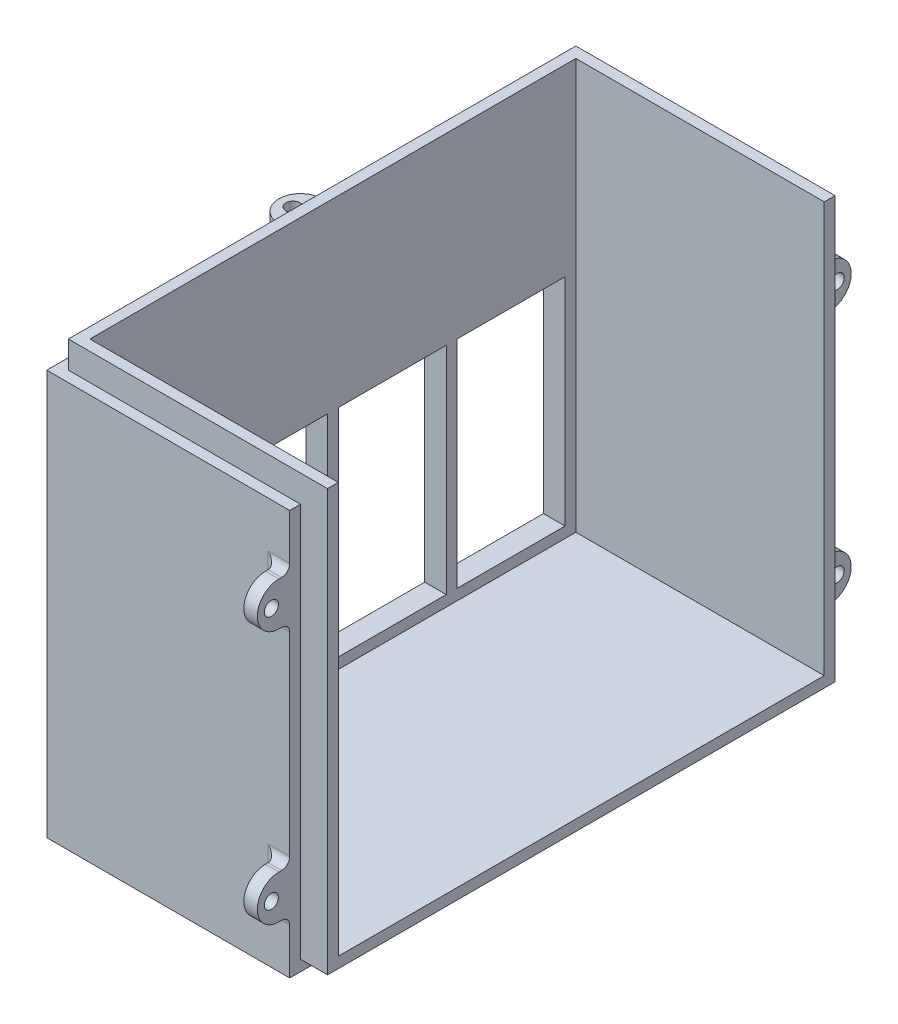
from build123d import *

# Parameters (mm, degrees)
SKETCH1_W           = 50
SKETCH1_H           = 98
BOSS_EXTRUDE3_DEPTH = 80
SKETCH4_W           = 90
SKETCH4_H           = 76
CUT_EXTRUDE2_DEPTH  = 46
SKETCH6_W           = 48
SKETCH6_H           = 2
CUT_EXTRUDE3_DEPTH  = 5
SKETCH7_W           = 2
SKETCH7_H           = 73
CUT_EXTRUDE4_DEPTH  = 5
SKETCH10_R          = 1.3
BOSS_EXTRUDE6_DEPTH = 2.5
FILLET2_R           = 1.5
FILLET3_R           = 1.5
SKETCH12_R          = 1.3
BOSS_EXTRUDE7_DEPTH = 2.5
FILLET4_R           = 1.5
CUT_EXTRUDE5_REACH  = 52
SKETCH14_W          = 20
SKETCH14_H          = 40


with BuildPart() as part:
    # Sketch1 → Boss-Extrude3 (new body)
    with BuildSketch(Plane(origin=(0, 0, 0), x_dir=(1, 0, 0), z_dir=(0, 1, 0))):
        Rectangle(SKETCH1_W, SKETCH1_H)
    extrude(amount=BOSS_EXTRUDE3_DEPTH)

    # Sketch4 → Cut-Extrude2 (cut)
    with BuildSketch(Plane(origin=(25, 0, 0), x_dir=(0, 0, -1), z_dir=(1, 0, 0))):
        with Locations((0, 42)):
            Rectangle(SKETCH4_W, SKETCH4_H)
    extrude(amount=-CUT_EXTRUDE2_DEPTH, mode=Mode.SUBTRACT)

    # Sketch6 → Cut-Extrude3 (cut)
    with BuildSketch(Plane(origin=(0, 80, 0), x_dir=(1, 0, 0), z_dir=(0, 1, 0))):
        with Locations((1, 48)):
            Rectangle(SKETCH6_W, SKETCH6_H)
        Polygon((-25, 49), (-25, -47), (-23, -47), (-23, 47), (-23, 49), align=None)
        Polygon((-25, -49), (25, -49), (25, -47), (-23, -47), (-25, -47), align=None)
    extrude(amount=-CUT_EXTRUDE3_DEPTH, mode=Mode.SUBTRACT)

    # Sketch7 → Cut-Extrude4 (cut)
    with BuildSketch(Plane(origin=(25, 0, 0), x_dir=(0, 0, -1), z_dir=(1, 0, 0))):
        Polygon((-47, 75), (-49, 75), (-49, 0), (-47, 0), (-47, 2), align=None)
        Polygon((47, 2), (-47, 2), (-47, 0), (49, 0), (49, 2), align=None)
        with Locations((48, 38.5)):
            Rectangle(SKETCH7_W, SKETCH7_H)
    extrude(amount=-CUT_EXTRUDE4_DEPTH, mode=Mode.SUBTRACT)

    # Sketch10 → Boss-Extrude6 (add)
    with BuildSketch(Plane(origin=(20, 0, 0), x_dir=(0, 0, -1), z_dir=(1, 0, 0))):
        with BuildLine():
            Line((-49, 10), (-51, 10))
            ThreePointArc((-51, 10), (-55, 14), (-51, 18))
            Line((-51, 18), (-49, 18))
            Line((-49, 18), (-49, 10))
        make_face()
        with Locations((-52.4, 14)):
            Circle(SKETCH10_R, mode=Mode.SUBTRACT)
        with BuildLine():
            Line((-49, 65), (-49, 57))
            Line((-49, 57), (-51, 57))
            ThreePointArc((-51, 57), (-55, 61), (-51, 65))
            Line((-51, 65), (-49, 65))
        make_face()
        with Locations((-52.4, 61)):
            Circle(SKETCH10_R, mode=Mode.SUBTRACT)
        with BuildLine():
            Line((49, 10), (49, 18))
            Line((49, 18), (51, 18))
            ThreePointArc((51, 18), (55, 14), (51, 10))
            Line((51, 10), (49, 10))
        make_face()
        with Locations((52.4, 14)):
            Circle(SKETCH10_R, mode=Mode.SUBTRACT)
        with BuildLine():
            Line((49, 65), (51, 65))
            ThreePointArc((51, 65), (55, 61), (51, 57))
            Line((51, 57), (49, 57))
            Line((49, 57), (49, 65))
        make_face()
        with Locations((52.4, 61)):
            Circle(SKETCH10_R, mode=Mode.SUBTRACT)
    extrude(amount=-BOSS_EXTRUDE6_DEPTH)

    # Fillet2
    fillet2_edges = [part.edges().sort_by_distance(p)[0] for p in [
        (17.5, 61, 49),
        (18.75, 65, 49),
        (18.75, 57, 49),
        (17.5, 14, 49),
        (18.75, 18, 49),
        (18.75, 10, 49),
    ]]
    fillet(fillet2_edges, radius=FILLET2_R)

    # Fillet3
    fillet3_edges = [part.edges().sort_by_distance(p)[0] for p in [
        (17.5, 14, -49),
        (18.75, 10, -49),
        (18.75, 18, -49),
        (17.5, 61, -49),
        (18.75, 57, -49),
        (18.75, 65, -49),
    ]]
    fillet(fillet3_edges, radius=FILLET3_R)

    # Sketch12 → Boss-Extrude7 (add)
    with BuildSketch(Plane(origin=(0, 75, 0), x_dir=(1, 0, 0), z_dir=(0, 1, 0))):
        with BuildLine():
            Line((-25, 4), (-27, 4))
            ThreePointArc((-27, 4), (-31, 0), (-27, -4))
            Line((-27, -4), (-25, -4))
            Line((-25, -4), (-25, 4))
        make_face()
        with Locations((-28.4, 0)):
            Circle(SKETCH12_R, mode=Mode.SUBTRACT)
    extrude(amount=-BOSS_EXTRUDE7_DEPTH)

    # Fillet4
    fillet4_edges = [part.edges().sort_by_distance(p)[0] for p in [
        (-25, 72.5, 0),
        (-25, 73.75, -4),
        (-25, 73.75, 4),
    ]]
    fillet(fillet4_edges, radius=FILLET4_R)

    # Sketch14 → Cut-Extrude5 (cut, up to next)
    with BuildSketch(Plane.ZY.offset(25), mode=Mode.PRIVATE) as cut_extrude5_sk1:
        with Locations((33, 26)):
            Rectangle(SKETCH14_W, SKETCH14_H)
    cut_extrude5_tool1 = extrude(cut_extrude5_sk1.sketch, amount=-CUT_EXTRUDE5_REACH, mode=Mode.PRIVATE) & part.part
    add(cut_extrude5_tool1.solids().sort_by_distance((-25, 26, 33))[0], mode=Mode.SUBTRACT)
    # Sketch14 → Cut-Extrude5 (cut, up to next)
    with BuildSketch(Plane.ZY.offset(25), mode=Mode.PRIVATE) as cut_extrude5_sk2:
        with Locations((11, 26)):
            Rectangle(SKETCH14_W, SKETCH14_H)
    cut_extrude5_tool2 = extrude(cut_extrude5_sk2.sketch, amount=-CUT_EXTRUDE5_REACH, mode=Mode.PRIVATE) & part.part
    add(cut_extrude5_tool2.solids().sort_by_distance((-25, 26, 11))[0], mode=Mode.SUBTRACT)
    # Sketch14 → Cut-Extrude5 (cut, up to next)
    with BuildSketch(Plane.ZY.offset(25), mode=Mode.PRIVATE) as cut_extrude5_sk3:
        with Locations((-11, 26)):
            Rectangle(SKETCH14_W, SKETCH14_H)
    cut_extrude5_tool3 = extrude(cut_extrude5_sk3.sketch, amount=-CUT_EXTRUDE5_REACH, mode=Mode.PRIVATE) & part.part
    add(cut_extrude5_tool3.solids().sort_by_distance((-25, 26, -11))[0], mode=Mode.SUBTRACT)
    # Sketch14 → Cut-Extrude5 (cut, up to next)
    with BuildSketch(Plane.ZY.offset(25), mode=Mode.PRIVATE) as cut_extrude5_sk4:
        with Locations((-33, 26)):
            Rectangle(SKETCH14_W, SKETCH14_H)
    cut_extrude5_tool4 = extrude(cut_extrude5_sk4.sketch, amount=-CUT_EXTRUDE5_REACH, mode=Mode.PRIVATE) & part.part
    add(cut_extrude5_tool4.solids().sort_by_distance((-25, 26, -33))[0], mode=Mode.SUBTRACT)


solid = part.part
